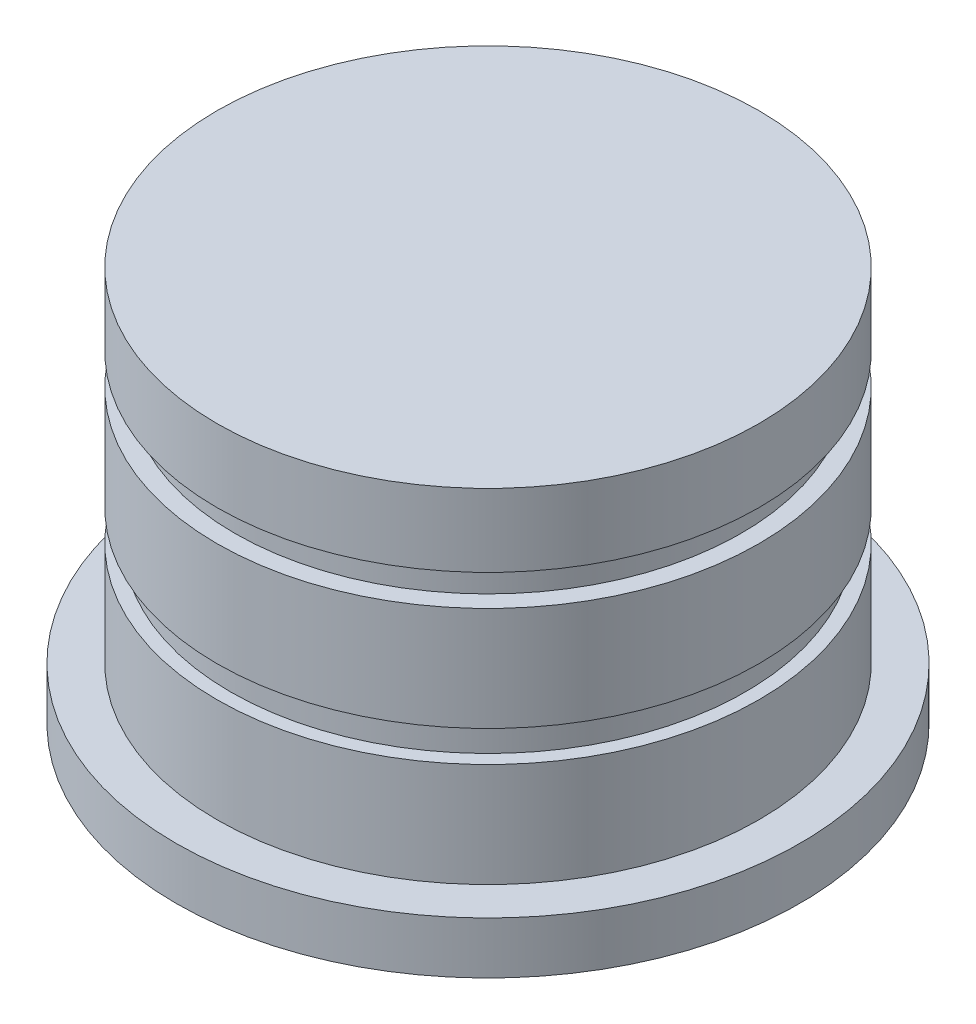
from build123d import *

# Parameters (mm, degrees)
SKETCH1_R           = 3000
BOSS_EXTRUDE1_DEPTH = 500
SKETCH2_R           = 2606.512121569
BOSS_EXTRUDE2_DEPTH = 1000
SKETCH3_R           = 2476.564065313
BOSS_EXTRUDE3_DEPTH = 300
SKETCH4_R           = 2606.512121569
BOSS_EXTRUDE4_DEPTH = 1000
SKETCH5_R           = 2435.427712843
BOSS_EXTRUDE5_DEPTH = 300
SKETCH6_R           = 2606.512121569
BOSS_EXTRUDE6_DEPTH = 700


with BuildPart() as part:
    # Sketch1 → Boss-Extrude1 (new body)
    with BuildSketch(Plane(origin=(0, 0, 0), x_dir=(1, 0, 0), z_dir=(0, 1, 0))):
        Circle(SKETCH1_R)
    extrude(amount=BOSS_EXTRUDE1_DEPTH)


with BuildPart() as body_2:
    # Sketch2 → Boss-Extrude2 (new body)
    with BuildSketch(Plane(origin=(0, 500, 0), x_dir=(1, 0, 0), z_dir=(0, 1, 0))):
        Circle(SKETCH2_R)
    extrude(amount=BOSS_EXTRUDE2_DEPTH)

    # Sketch3 → Boss-Extrude3 (add)
    with BuildSketch(Plane(origin=(0, 1500, 0), x_dir=(1, 0, 0), z_dir=(0, 1, 0))):
        Circle(SKETCH3_R)
    extrude(amount=BOSS_EXTRUDE3_DEPTH)

    # Sketch4 → Boss-Extrude4 (add)
    with BuildSketch(Plane(origin=(0, 1800, 0), x_dir=(1, 0, 0), z_dir=(0, 1, 0))):
        Circle(SKETCH4_R)
    extrude(amount=BOSS_EXTRUDE4_DEPTH)

    # Sketch5 → Boss-Extrude5 (add)
    with BuildSketch(Plane(origin=(0, 2800, 0), x_dir=(1, 0, 0), z_dir=(0, 1, 0))):
        Circle(SKETCH5_R)
    extrude(amount=BOSS_EXTRUDE5_DEPTH)

    # Sketch6 → Boss-Extrude6 (add)
    with BuildSketch(Plane(origin=(0, 3100, 0), x_dir=(1, 0, 0), z_dir=(0, 1, 0))):
        Circle(SKETCH6_R)
    extrude(amount=BOSS_EXTRUDE6_DEPTH)


solid = Compound([part.part, body_2.part])
